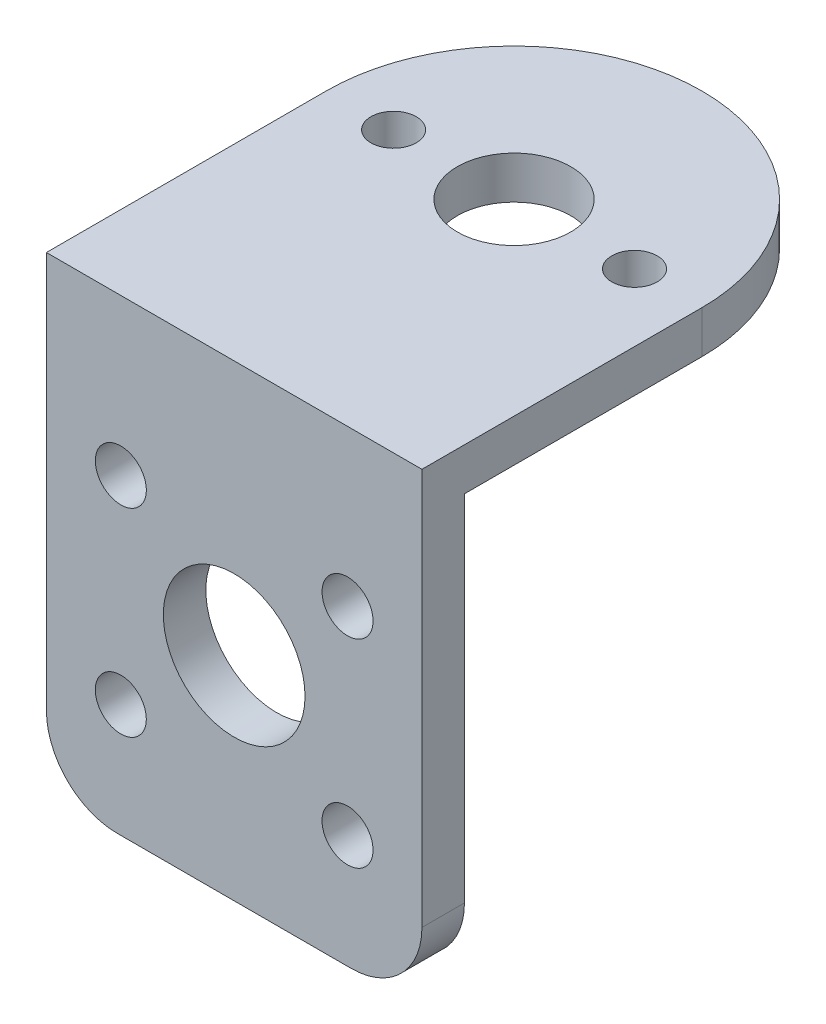
from build123d import *

# Parameters (mm, degrees)
SKETCH_1_R      = 5
SKETCH_1_R_2    = 1.8
EXTRUDE_1_DEPTH = 3
SKETCH_3_R      = 4
SKETCH_3_R_2    = 1.6
EXTRUDE_2_DEPTH = 3


with BuildPart() as part:
    # 草图1 → 凸台-拉伸1 (new body)
    with BuildSketch(Plane.XY):
        with BuildLine():
            Line((5, 0), (21.5, 0))
            ThreePointArc((21.5, 0), (25.035533906, 1.464466094), (26.5, 5))
            Line((26.5, 5), (26.5, 30))
            Line((26.5, 30), (0, 30))
            Line((0, 30), (0, 5))
            ThreePointArc((0, 5), (1.464466094, 1.464466094), (5, 0))
        make_face()
        with Locations((13.25, 15)):
            Circle(SKETCH_1_R, mode=Mode.SUBTRACT)
        with Locations((5.25, 8)):
            Circle(SKETCH_1_R_2, mode=Mode.SUBTRACT)
        with Locations((5.25, 22)):
            Circle(SKETCH_1_R_2, mode=Mode.SUBTRACT)
        with Locations((21.25, 8)):
            Circle(SKETCH_1_R_2, mode=Mode.SUBTRACT)
        with Locations((21.25, 22)):
            Circle(SKETCH_1_R_2, mode=Mode.SUBTRACT)
    extrude(amount=EXTRUDE_1_DEPTH)

    # 草图3 → 凸台-拉伸2 (add)
    with BuildSketch(Plane(origin=(0, 30, 0), x_dir=(1, 0, 0), z_dir=(0, 1, 0))):
        with BuildLine():
            Line((0, -3), (26.5, -3))
            Line((26.5, -3), (26.5, 16.75))
            ThreePointArc((26.5, 16.75), (13.25, 30), (0, 16.75))
            Line((0, 16.75), (0, -3))
        make_face()
        with Locations((13.25, 16.75)):
            Circle(SKETCH_3_R, mode=Mode.SUBTRACT)
        with Locations((21.75, 16.75)):
            Circle(SKETCH_3_R_2, mode=Mode.SUBTRACT)
        with Locations((4.75, 16.75)):
            Circle(SKETCH_3_R_2, mode=Mode.SUBTRACT)
    extrude(amount=EXTRUDE_2_DEPTH)


solid = part.part
